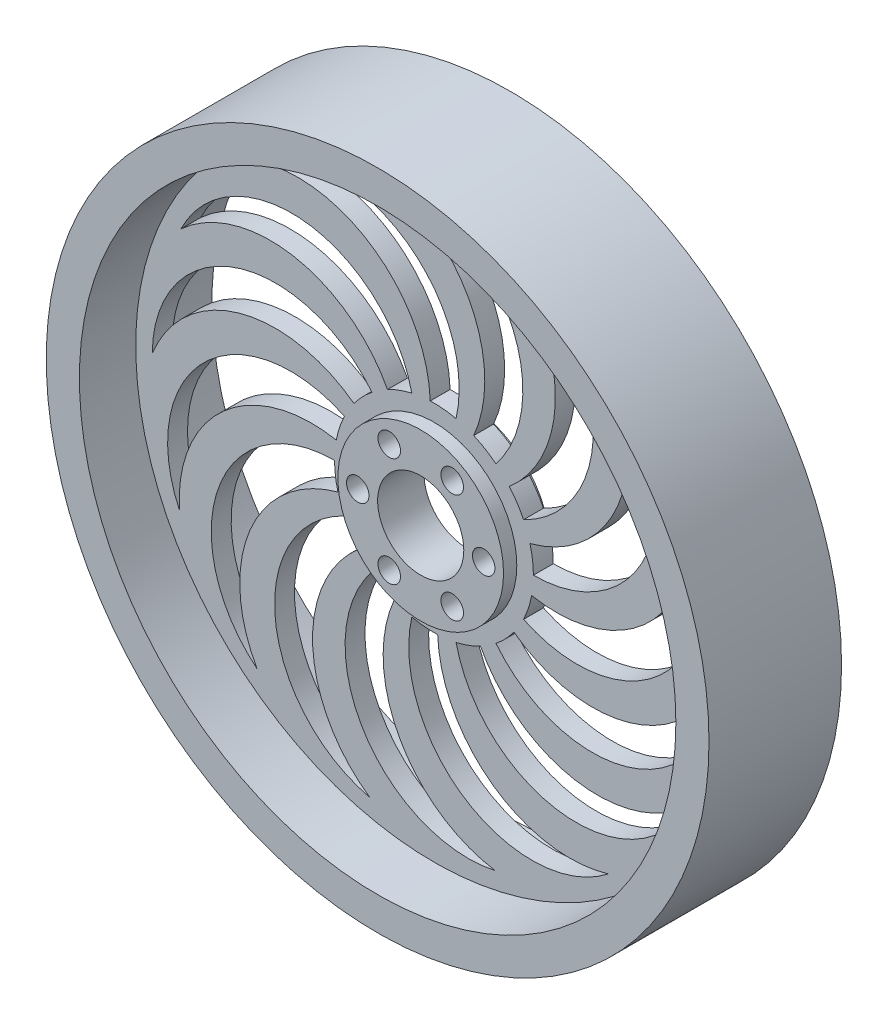
from build123d import *

# Parameters (mm, degrees)
SKETCH1_W            = 32.5
SKETCH1_H            = 3
SKETCH1_W_2          = 6
SKETCH1_H_2          = 7
M3_CLEARANCE_HOLE1_D = 3.4
CUT_EXTRUDE1_DEPTH   = 12.5
CIRPATTERN1_COUNT    = 14


with BuildPart() as part:
    # Sketch1 → Revolve1 (revolve)
    with BuildSketch(Plane(origin=(0, 0, 0), x_dir=(1, 0, 0), z_dir=(0, 1, 0))):
        Polygon((45, 1.5), (45, -1.5), (45, -10), (50, -10), (50, 10), (45, 10), align=None)
        with Locations((28.75, 0)):
            Rectangle(SKETCH1_W, SKETCH1_H)
        with Locations((9.5, 0)):
            Rectangle(SKETCH1_W_2, SKETCH1_H_2)
    revolve(axis=Axis((0, 0, 77.742212382), (0, 0, -1)))

    # M3 Clearance Hole1 (through all)
    with Locations(Plane.XY.offset(3.5)):
        with Locations((-4.75, 8.227241336), (4.75, 8.227241336), (9.5, 0), (4.75, -8.227241336), (-4.75, -8.227241336), (-9.5, 0)):
            Hole(M3_CLEARANCE_HOLE1_D / 2)

    # Sketch5 → Cut-Extrude1 (cut, through all)
    with BuildSketch(Plane.XY.offset(1.5)):
        with BuildLine():
            ThreePointArc((14.488887394, 3.882285677), (14.871672921, 1.957892883), (15, 0))
            ThreePointArc((15, 0), (32.542393706, 12.411508104), (26.676923077, 33.084615385))
            ThreePointArc((26.676923077, 33.084615385), (27.759031054, 15.488385465), (14.488887394, 3.882285677))
        make_face()
    cut_extrude1 = extrude(amount=-CUT_EXTRUDE1_DEPTH, mode=Mode.SUBTRACT)

    # CirPattern1: Cut-Extrude1 ×14 about axis
    cirpattern1_axis = Axis((0, 0, 0), (0, 0, 1))
    for i in range(1, CIRPATTERN1_COUNT):
        add(cut_extrude1.rotate(cirpattern1_axis, i * 360 / CIRPATTERN1_COUNT), mode=Mode.SUBTRACT)


solid = part.part
